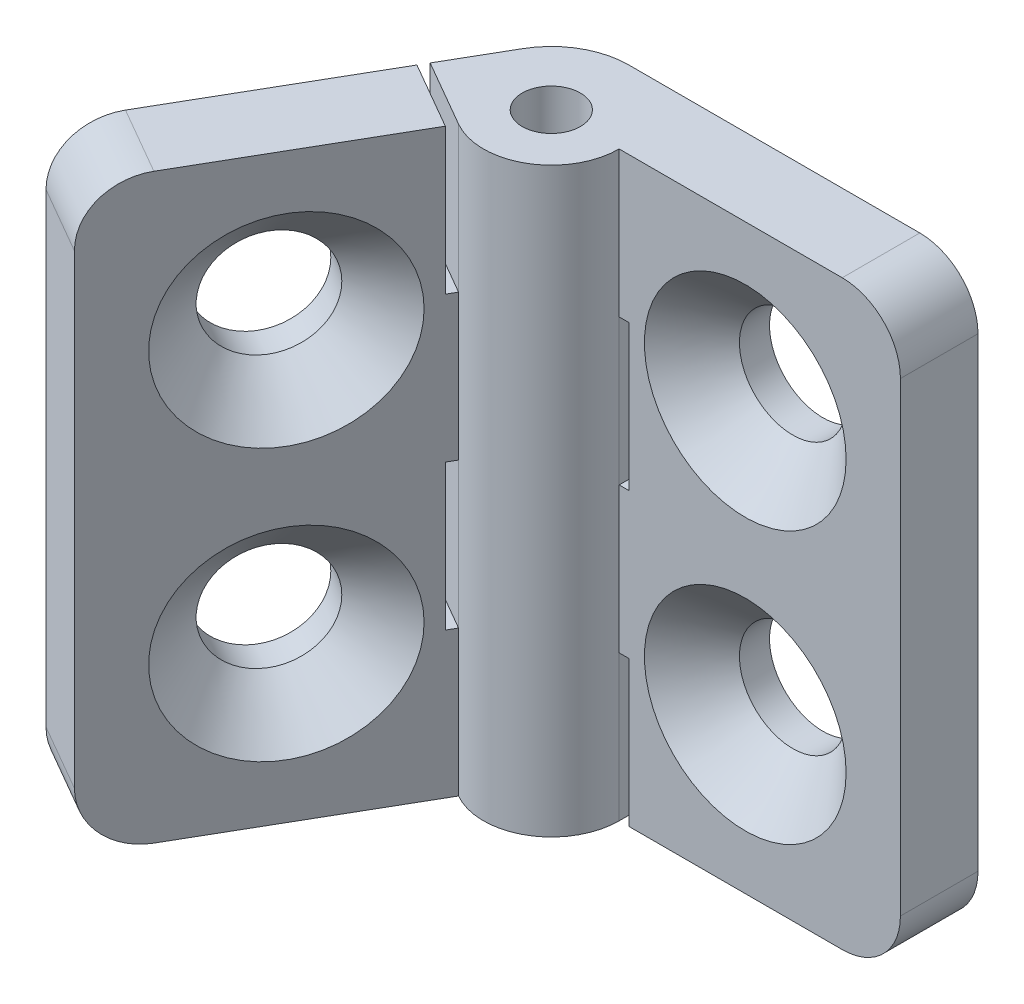
from build123d import *

# Parameters (mm, degrees)
SKETCH_9_R                  = 1.5
EXTRUDE_4_DEPTH             = 15
EXTRUDE_4_DEPTH_BACK        = 15
EXTRUDE_5_REACH             = 17
SKETCH_10_R                 = 1.5
EXTRUDE_5_DIRECTION_2_REACH = 17
HOLE_WIZARD_M52_AT_2_COUNT  = 2
HOLE_WIZARD_M52_AT_2_PITCH  = 14
HOLE_WIZARD_M51_D           = 5.5
HOLE_WIZARD_M51_CSINK_D     = 10.4
HOLE_WIZARD_M51_CSINK_ANGLE = 90
CUT_EXTRUDE_3_DEPTH         = 16
CUT_EXTRUDE_3_DEPTH_BACK    = 16
SKETCH_25_W                 = 0.5
SKETCH_25_H                 = 7.5
CUT_EXTRUDE_7_DEPTH         = 13.794228634
SKETCH_27_W                 = 0.5
SKETCH_27_H                 = 7.5
CUT_EXTRUDE_8_DEPTH         = 5
FILLET_4_R                  = 3


with BuildPart() as part:
    # Sketch 9 → Extrude 4 (new body, two sides)
    with BuildSketch(Plane(origin=(0, 0, 0), x_dir=(1, 0, 0), z_dir=(0, 1, 0))) as extrude_4_sk:
        with BuildLine():
            Line((0, 4), (18, 4))
            Line((18, 4), (18, 0))
            Line((18, 0), (4, 0))
            ThreePointArc((4, 0), (-2.828427125, -2.828427125), (0, 4))
        make_face()
        with Locations(Location((0, 0, 0), (0, 0, 270))):  # turned: the seam where the file's is
            Circle(SKETCH_9_R, mode=Mode.SUBTRACT)
    extrude(amount=EXTRUDE_4_DEPTH)
    extrude(extrude_4_sk.sketch, amount=-EXTRUDE_4_DEPTH_BACK)

    # Extrude 5: up to this face of the body (flat: up to its plane)
    extrude_5_end = Plane(part.part.faces().sort_by_distance((6.10604541, 15, -1.19522591))[0])
    # Sketch 10 → Extrude 5 (add, up to the picked face)
    with BuildSketch(Plane(origin=(0, 0, 0), x_dir=(1, 0, 0), z_dir=(0, 1, 0)), mode=Mode.PRIVATE) as extrude_5_sk1:
        with BuildLine():
            Line((-3.464101615, 2), (-12.464101615, -13.588457268))
            Line((-12.464101615, -13.588457268), (-9, -15.588457268))
            Line((-9, -15.588457268), (-2, -3.464101615))
            ThreePointArc((-2, -3.464101615), (3.863703305, 1.03527618), (-3.464101615, 2))
        make_face()
        with Locations(Location((0, 0, 0), (0, 0, 270))):  # turned: the seam where the file's is
            Circle(SKETCH_10_R, mode=Mode.SUBTRACT)
    extrude_5_tool1 = split(extrude(extrude_5_sk1.sketch, amount=EXTRUDE_5_REACH, mode=Mode.PRIVATE), bisect_by=extrude_5_end, keep=Keep.BOTH, mode=Mode.PRIVATE)
    add(extrude_5_tool1.solids().sort_by(Axis((-4.088119, 0, 4.690377), (0, 1, 0)))[0])

    # Extrude 5 direction 2: up to this face of the body (flat: up to its plane)
    extrude_5_direction_2_end = Plane(part.part.faces().sort_by_distance((6.10604541, -15, -1.19522591))[0])
    # Sketch 10 → Extrude 5 direction 2 (add, up to the picked face)
    with BuildSketch(Plane(origin=(0, 0, 0), x_dir=(1, 0, 0), z_dir=(0, 1, 0)), mode=Mode.PRIVATE) as extrude_5_direction_2_sk1:
        with BuildLine():
            Line((-3.464101615, 2), (-12.464101615, -13.588457268))
            Line((-12.464101615, -13.588457268), (-9, -15.588457268))
            Line((-9, -15.588457268), (-2, -3.464101615))
            ThreePointArc((-2, -3.464101615), (3.863703305, 1.03527618), (-3.464101615, 2))
        make_face()
        with Locations(Location((0, 0, 0), (0, 0, 270))):  # turned: the seam where the file's is
            Circle(SKETCH_10_R, mode=Mode.SUBTRACT)
    extrude_5_direction_2_tool1 = split(extrude(extrude_5_direction_2_sk1.sketch, amount=-EXTRUDE_5_DIRECTION_2_REACH, mode=Mode.PRIVATE), bisect_by=extrude_5_direction_2_end, keep=Keep.BOTH, mode=Mode.PRIVATE)
    add(extrude_5_direction_2_tool1.solids().sort_by(Axis((-4.088119, 0, 4.690377), (0, -1, 0)))[0])

    # Sketch 12 → Hole Wizard M52 (revolve, cut)
    with BuildSketch(Plane(origin=(10, 7, 0), x_dir=(0, -1, 0), z_dir=(1, 0, 0))):
        Polygon((0, 0), (0, 4), (2.75, 4), (2.75, 2.45), (5.2, 0), align=None)
    hole_wizard_m52 = revolve(axis=Axis((10, 7, 6.35), (0, 0, -1)), mode=Mode.SUBTRACT)

    # Hole Wizard M52 at 2: Hole Wizard M52 ×2
    with Locations(*[(0, -i * HOLE_WIZARD_M52_AT_2_PITCH, 0) for i in range(1, HOLE_WIZARD_M52_AT_2_COUNT)]):
        add(hole_wizard_m52, mode=Mode.SUBTRACT)

    # Hole Wizard M51 (through all)
    with Locations(Plane(origin=(0, 0, 0), x_dir=(0.5, 0, -0.866025404), z_dir=(0.866025404, 0, 0.5))):
        with Locations((-10, 7), (-10, -7)):
            CounterSinkHole(HOLE_WIZARD_M51_D / 2, HOLE_WIZARD_M51_CSINK_D / 2, counter_sink_angle=HOLE_WIZARD_M51_CSINK_ANGLE)

    # Sketch 17 → Cut-Extrude 3 (cut, two sides)
    with BuildSketch(Plane(origin=(0, 0, 0), x_dir=(1, 0, 0), z_dir=(0, 1, 0))) as cut_extrude_3_sk:
        with BuildLine():
            Line((-2, -3.464101615), (-1.75, -3.031088913))
            ThreePointArc((-1.75, -3.031088913), (1.75, -3.031088913), (3.5, 0))
            Line((3.5, 0), (4, 0))
            ThreePointArc((4, 0), (2, -3.464101615), (-2, -3.464101615))
        make_face()
    extrude(amount=CUT_EXTRUDE_3_DEPTH, mode=Mode.SUBTRACT)
    extrude(cut_extrude_3_sk.sketch, amount=-CUT_EXTRUDE_3_DEPTH_BACK, mode=Mode.SUBTRACT)

    # Sketch 25 → Cut-Extrude 7 (cut, through all)
    with BuildSketch(Plane(origin=(0, 0, 0), x_dir=(0.5, 0, -0.866025404), z_dir=(0.866025404, 0, 0.5))):
        with Locations((-3.75, 11.25)):
            Rectangle(SKETCH_25_W, SKETCH_25_H)
        with Locations((-3.75, -3.75)):
            Rectangle(SKETCH_25_W, SKETCH_25_H)
    extrude(amount=-CUT_EXTRUDE_7_DEPTH, mode=Mode.SUBTRACT)

    # Sketch 27 → Cut-Extrude 8 (cut, through all)
    with BuildSketch(Plane.XY):
        with Locations((3.75, 3.75)):
            Rectangle(SKETCH_27_W, SKETCH_27_H)
        with Locations((3.75, -11.25)):
            Rectangle(SKETCH_27_W, SKETCH_27_H)
    extrude(amount=-CUT_EXTRUDE_8_DEPTH, mode=Mode.SUBTRACT)

    # Fillet 4
    fillet_4_edges = [part.edges().sort_by_distance(p)[0] for p in [
        (18, -15, -2),
        (18, 15, -2),
        (-10.732050808, 15, 14.588457268),
        (-10.732050808, -15, 14.588457268),
    ]]
    fillet(fillet_4_edges, radius=FILLET_4_R)


solid = part.part
